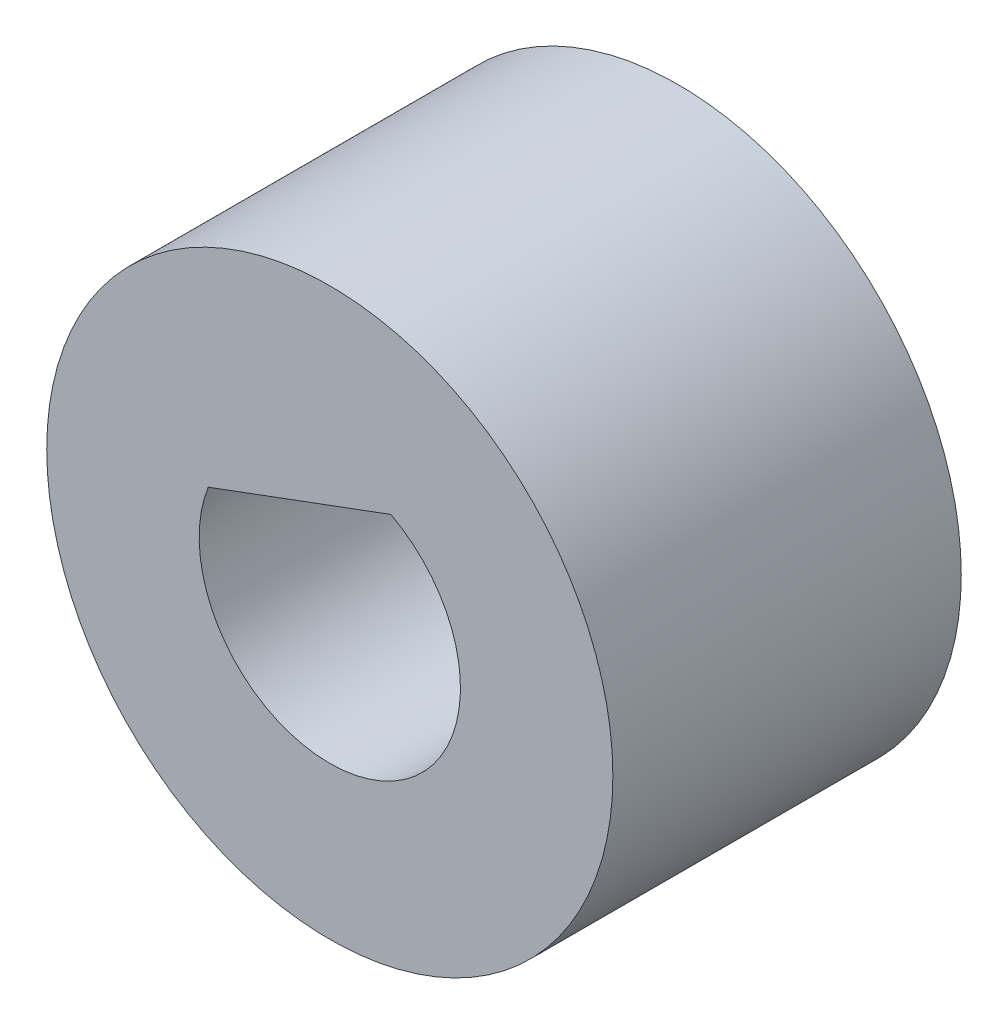
from build123d import *

# Parameters (mm, degrees)
SKETCH1_R           = 3.25
SKETCH1_R_2         = 1.5
BOSS_EXTRUDE1_DEPTH = 4
BOSS_EXTRUDE2_DEPTH = 4


with BuildPart() as part:
    # Sketch1 → Boss-Extrude1 (new body)
    with BuildSketch(Plane.XY):
        Circle(SKETCH1_R)
        Circle(SKETCH1_R_2, mode=Mode.SUBTRACT)
    extrude(amount=BOSS_EXTRUDE1_DEPTH)

    # Sketch2 → Boss-Extrude2 (add)
    with BuildSketch(Plane.XY.offset(4)):
        with BuildLine():
            ThreePointArc((0.700849555, 1.326201305), (-0.521259053, 1.406516619), (-1.395861626, 0.549154187))
            Line((-1.395861626, 0.549154187), (0.700849555, 1.326201305))
        make_face()
    extrude(amount=-BOSS_EXTRUDE2_DEPTH)


solid = part.part
